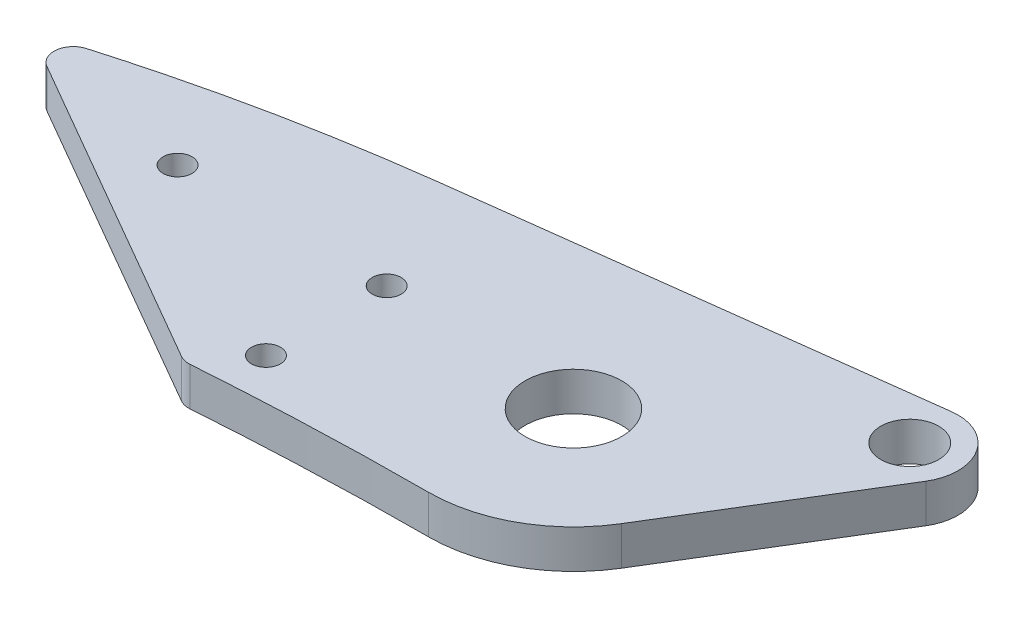
from build123d import *

# Parameters (mm, degrees)
SKETCH1_R           = 1.5
BOSS_EXTRUDE4_DEPTH = 4
SKETCH2_R           = 3
BOSS_EXTRUDE6_DEPTH = 4
CUT_EXTRUDE4_DEPTH  = 5.0000001
FILLET4_R           = 2
SKETCH7_R           = 5
SKETCH7_R_2         = 1.5
CUT_EXTRUDE3_DEPTH  = 10


with BuildPart() as part:
    # Sketch1 → Boss-Extrude4 (new body)
    with BuildSketch(Plane(origin=(0, 0, 0), x_dir=(1, 0, 0), z_dir=(0, 1, 0))):
        with BuildLine():
            add(Edge.make_bspline(
                [(0, 15), (-53.333333333, 15), (-97.583223813, -2.850327116), (-150.232513174, -43.74649777)],
                knots=[0, 0, 0, 0, 1, 1, 1, 1], degree=3))
            Line((-150.232513174, -43.74649777), (-144.167389057, -51.554673195))
            add(Edge.make_bspline(
                [(0, -15), (-49.211171611, -15), (-112.57781544, -27.016970802), (-144.167389057, -51.554673195)],
                knots=[0, 0, 0, 0, 1, 1, 1, 1], degree=3))
            ThreePointArc((0, -15), (15, 0), (0, 15))
        make_face()
        with Locations((-143.201136916, -44.647893409)):
            Circle(SKETCH1_R, mode=Mode.SUBTRACT)
    extrude(amount=BOSS_EXTRUDE4_DEPTH)

    # Sketch2 → Boss-Extrude6 (add)
    with BuildSketch(Plane.XZ):
        with BuildLine():
            Line((24.745562632, -11.732737533), (12.800284575, 7.820020128))
            ThreePointArc((12.800284575, 7.820020128), (14.439602983, 4.061756478), (15, 0))
            ThreePointArc((15, 0), (10.606601718, -10.606601718), (0, -15))
            add(Edge.make_bspline(
                [(0, -15), (-9.352958156, -15), (-18.426564807, -14.451032409), (-27.315109341, -13.325076493)],
                knots=[0, 0, 0, 0, 0.175367965, 0.175367965, 0.175367965, 0.175367965], degree=3))
            Line((-27.315109341, -13.325076493), (19.850447753, -19.299770983))
            ThreePointArc((19.850447753, -19.299770983), (24.676955739, -17.055197662), (24.745562632, -11.732737533))
        make_face()
        with Locations((20.478801107, -14.339410909)):
            Circle(SKETCH2_R, mode=Mode.SUBTRACT)
    extrude(amount=-BOSS_EXTRUDE6_DEPTH)

    # Sketch8 → Cut-Extrude4 (cut, through all)
    with BuildSketch(Plane(origin=(0, 4, 0), x_dir=(1, 0, 0), z_dir=(0, 1, 0))):
        Polygon((-61.93012476, 5.733160203), (-24.428772421, -15.918255665), (-81.418617577, -101.346773657), (-136.224202564, -112.686812452), (-181.390604498, 23.006558879), align=None)
    extrude(amount=-CUT_EXTRUDE4_DEPTH, mode=Mode.SUBTRACT)

    # Fillet4
    fillet4_edges = [part.edges().sort_by_distance(p)[0] for p in [
        (-61.93012476, 2, -5.733160203),
        (-24.428772421, 2, 15.918255665),
    ]]
    fillet(fillet4_edges, radius=FILLET4_R)

    # Sketch7 → Cut-Extrude3 (cut)
    with BuildSketch(Plane(origin=(0, 4, 0), x_dir=(1, 0, 0), z_dir=(0, 1, 0))):
        Circle(SKETCH7_R)
        with Locations((-42.326653454, 1.343293998)):
            Circle(SKETCH7_R_2)
        with Locations((-20.67601836, -11.156706002)):
            Circle(SKETCH7_R_2)
        with Locations((-20.67601836, 1.343293998)):
            Circle(SKETCH7_R_2)
    extrude(amount=-CUT_EXTRUDE3_DEPTH, mode=Mode.SUBTRACT)


solid = part.part
